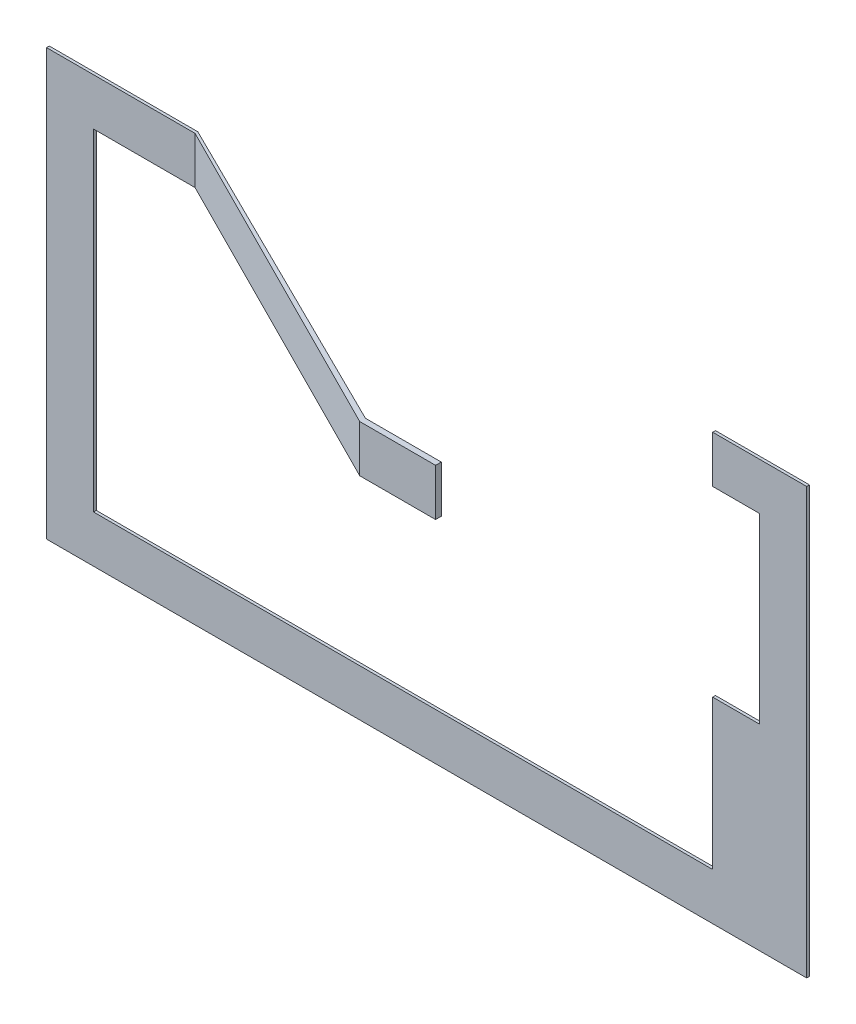
from build123d import *

# Parameters (mm, degrees)
EXTRUDE1_DEPTH = 50
EXTRUDE2_DEPTH = 850


with BuildPart() as part:
    # Sketch1 → Extrude1 (new body)
    with BuildSketch(Plane.XY):
        Polygon((-9214.463982447, 6700), (-9214.463982447, 5850), (-11050, 5850), (-11050, -150), (150, -150), (150, 2550), (1000, 2550), (1000, 5850), (150, 5850), (150, 6700), (1850, 6700), (1850, -1000), (-11900, -1000), (-11900, 6700), align=None)
    extrude(amount=-EXTRUDE1_DEPTH)

    # Sketch2 → Extrude2 (add)
    with BuildSketch(Plane(origin=(0, 6700, 0), x_dir=(1, 0, 0), z_dir=(0, 1, 0))):
        Polygon((-9214.463982447, 0), (-3210.139096843, -3025), (-1837.698532175, -3025), (-1837.698532175, -2922.061836858), (-3210.139096843, -2922.061836858), (-9214.463982447, 50), align=None)
    extrude(amount=-EXTRUDE2_DEPTH)


solid = part.part
